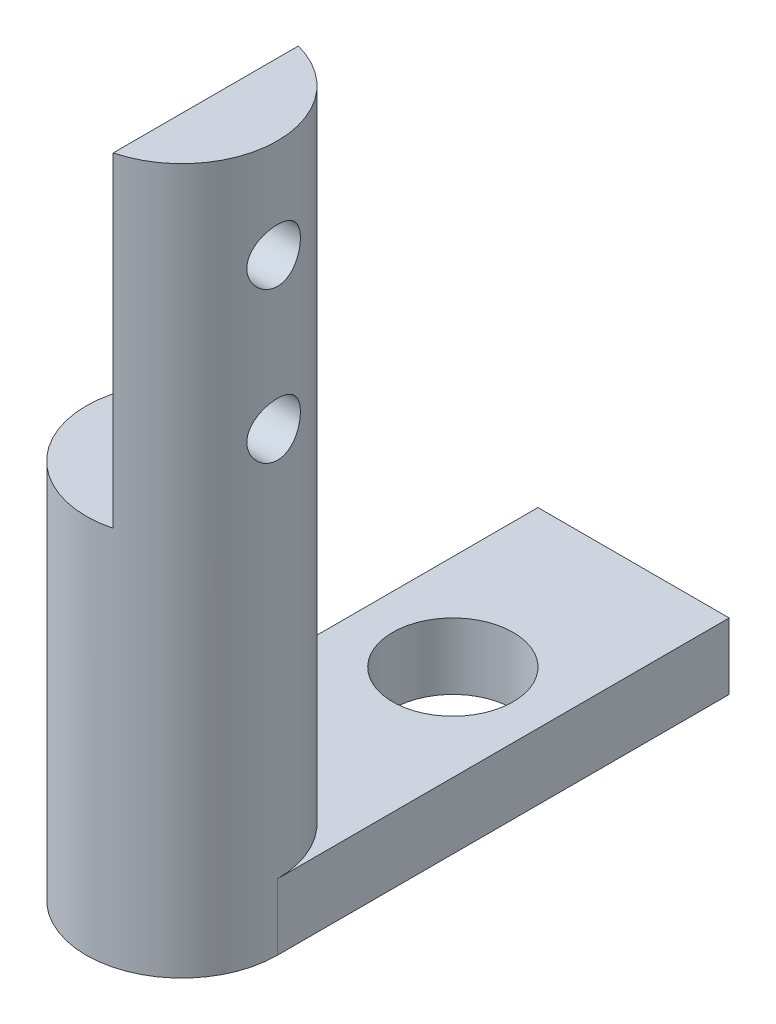
from build123d import *

# Parameters (mm, degrees)
SKETCH_1_R          = 3.175
EXTRUDE_1_DEPTH     = 57.15
CUT_EXTRUDE_1_DEPTH = 10.795
SKETCH_3_R          = 0.889
CUT_EXTRUDE_2_DEPTH = 10.795
SKETCH_4_R          = 3.175
CUT_EXTRUDE_3_DEPTH = 34.83
SKETCH_5_R          = 2
EXTRUDE_2_DEPTH     = 1.1


with BuildPart() as part:
    # 草图1 → 凸台-拉伸1 (new body)
    with BuildSketch(Plane(origin=(0, 0, 0), x_dir=(1, 0, 0), z_dir=(0, 1, 0))):
        Circle(SKETCH_1_R)
    extrude(amount=EXTRUDE_1_DEPTH)

    # 草图2 → 切除-拉伸1 (cut)
    with BuildSketch(Plane(origin=(0, 57.15, 0), x_dir=(1, 0, 0), z_dir=(0, 1, 0))):
        Polygon((-0.794, 3.175), (0.794, 3.175), (0.794, -3.175), (-3.175, -3.175), (-3.175, 3.175), align=None)
    extrude(amount=-CUT_EXTRUDE_1_DEPTH, mode=Mode.SUBTRACT)

    # 草图3 → 切除-拉伸2 (cut)
    with BuildSketch(Plane.ZY.offset(-0.794)):
        with Locations((0, 53.855)):
            Circle(SKETCH_3_R)
        with Locations((0, 48.855)):
            Circle(SKETCH_3_R)
    extrude(amount=-CUT_EXTRUDE_2_DEPTH, mode=Mode.SUBTRACT)

    # 草图4 → 切除-拉伸3 (cut)
    with BuildSketch(Plane.XZ):
        Circle(SKETCH_4_R)
    extrude(amount=-CUT_EXTRUDE_3_DEPTH, mode=Mode.SUBTRACT)

    # 草图5 → 凸台-拉伸2 (add, symmetric)
    with BuildSketch(Plane.XZ.offset(-34.83)):
        with BuildLine():
            Line((3.175, 0), (3.175, -15))
            Line((3.175, -15), (-3.175, -15))
            Line((-3.175, -15), (-3.175, 0))
            ThreePointArc((-3.175, 0), (0, 3.175), (3.175, 0))
        make_face()
        with Locations((0, -9)):
            Circle(SKETCH_5_R, mode=Mode.SUBTRACT)
    extrude(amount=EXTRUDE_2_DEPTH, both=True)


solid = part.part
